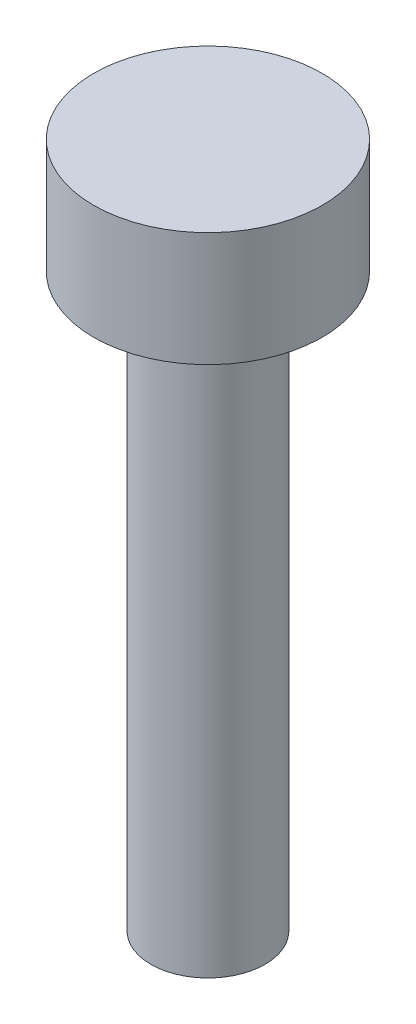
from build123d import *

# Parameters (mm, degrees)
SKETCH1_R           = 1.27
BOSS_EXTRUDE1_DEPTH = 12.7
SKETCH2_R           = 2.54
BOSS_EXTRUDE2_DEPTH = 2.54


with BuildPart() as part:
    # Sketch1 → Boss-Extrude1 (new body)
    with BuildSketch(Plane(origin=(0, 0, 0), x_dir=(1, 0, 0), z_dir=(0, 1, 0))):
        Circle(SKETCH1_R)
    extrude(amount=BOSS_EXTRUDE1_DEPTH)

    # Sketch2 → Boss-Extrude2 (add)
    with BuildSketch(Plane(origin=(0, 12.7, 0), x_dir=(1, 0, 0), z_dir=(0, 1, 0))):
        Circle(SKETCH2_R)
    extrude(amount=BOSS_EXTRUDE2_DEPTH)


solid = part.part
